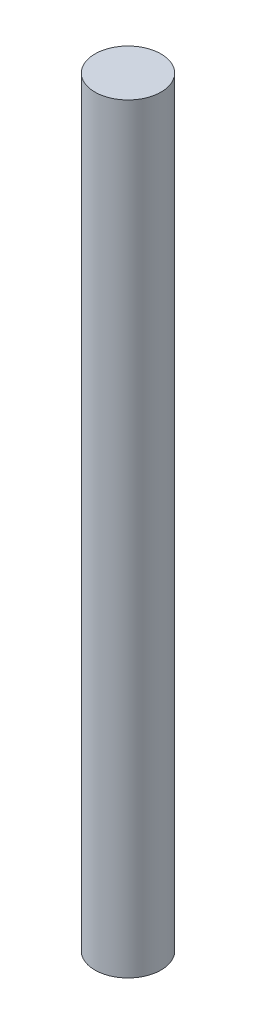
from build123d import *

# Parameters (mm, degrees)
SKETCH_1_R      = 1
EXTRUDE_1_DEPTH = 23


with BuildPart() as part:
    # Эскиз1 → Бобышка-Вытянуть1 (new body)
    with BuildSketch(Plane(origin=(0, 0, 0), x_dir=(1, 0, 0), z_dir=(0, 1, 0))):
        Circle(SKETCH_1_R)
    extrude(amount=EXTRUDE_1_DEPTH)


solid = part.part
